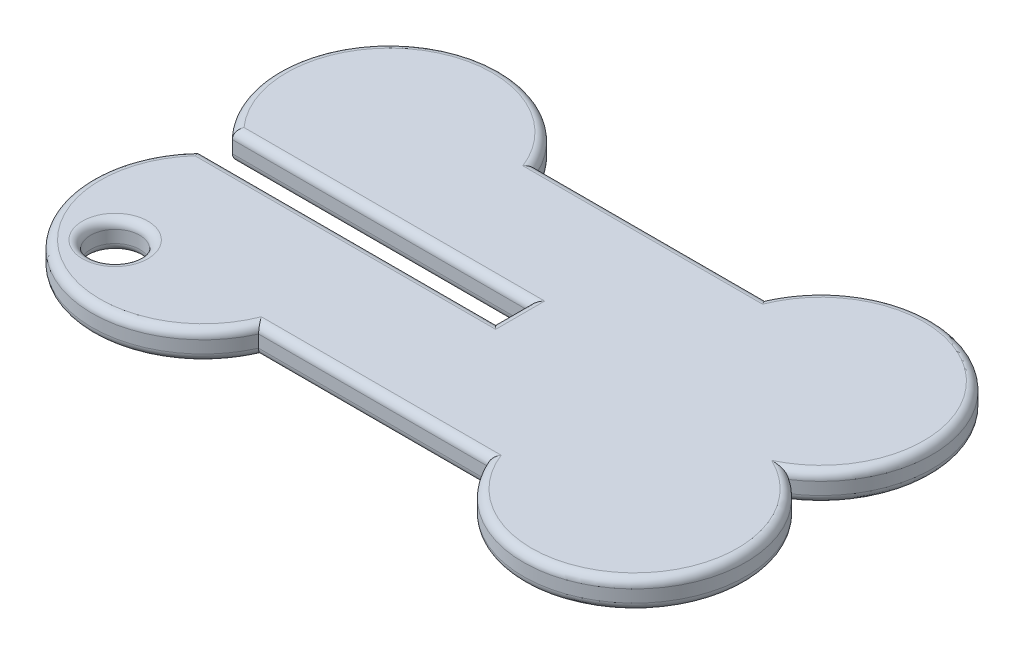
from build123d import *

# Parameters (mm, degrees)
BOSS_EXTRUDE1_DEPTH     = 4.445
SKETCH2_R               = 3.81
CUT_EXTRUDE1_DEPTH      = 152.70955658
CUT_EXTRUDE1_DEPTH_BACK = 152.70955658
FILLET2_R               = 1.27


with BuildPart() as part:
    # Sketch1 → Boss-Extrude1 (new body)
    with BuildSketch(Plane(origin=(0, 0, 0), x_dir=(1, 0, 0), z_dir=(0, 1, 0))):
        with BuildLine():
            Line((-61.139986431, -25.187895035), (-96.716377793, -25.187895035))
            ThreePointArc((-96.716377793, -25.187895035), (-123.704360598, -19.192627404), (-121.874754191, -46.777895035))
            ThreePointArc((-121.874754191, -46.777895035), (-123.704360598, -74.363162665), (-96.716377793, -68.367895035))
            Line((-96.716377793, -68.367895035), (-61.139986431, -68.367895035))
            ThreePointArc((-61.139986431, -68.367895035), (-34.152003626, -74.363162665), (-35.981610034, -46.777895035))
            ThreePointArc((-35.981610034, -46.777895035), (-34.152003626, -19.192627404), (-61.139986431, -25.187895035))
        make_face()
    extrude(amount=BOSS_EXTRUDE1_DEPTH)

    # Sketch2 → Cut-Extrude1 (cut, two sides)
    with BuildSketch(Plane(origin=(0, 4.445, 0), x_dir=(1, 0, 0), z_dir=(0, 1, 0))) as cut_extrude1_sk:
        with BuildLine():
            Line((-78.928182112, -44.237895035), (-124.938415086, -44.237895035))
            ThreePointArc((-124.938415086, -44.237895035), (-123.479984337, -45.596427234), (-121.874754191, -46.777895035))
            ThreePointArc((-121.874754191, -46.777895035), (-123.479984337, -47.959362836), (-124.938415086, -49.317895035))
            Line((-124.938415086, -49.317895035), (-78.928182112, -49.317895035))
            Line((-78.928182112, -49.317895035), (-78.928182112, -44.237895035))
        make_face()
        with Locations(Location((-119.259455088, -68.117887971, 0), (0, 0, 270))):
            Circle(SKETCH2_R)
    extrude(amount=CUT_EXTRUDE1_DEPTH, mode=Mode.SUBTRACT)
    extrude(cut_extrude1_sk.sketch, amount=-CUT_EXTRUDE1_DEPTH_BACK, mode=Mode.SUBTRACT)

    # Fillet2
    fillet2_edges = [part.edges().sort_by_distance(p)[0] for p in [
        (-34.152003626, 0, 19.192627404),
        (-34.152003626, 4.445, 19.192627404),
        (-34.152003626, 0, 74.363162665),
        (-34.152003626, 4.445, 74.363162665),
        (-78.928182112, 0, 25.187895035),
        (-78.928182112, 4.445, 25.187895035),
        (-78.928182112, 0, 68.367895035),
        (-122.119440764, 0, 75.571739971),
        (-101.933298599, 0, 49.317895035),
        (-78.928182112, 0, 46.777895035),
        (-101.933298599, 0, 44.237895035),
        (-122.119440764, 0, 17.984050099),
        (-119.259455088, 0, 64.307887971),
        (-78.928182112, 4.445, 68.367895035),
        (-122.119440764, 4.445, 75.571739971),
        (-101.933298599, 4.445, 49.317895035),
        (-78.928182112, 4.445, 46.777895035),
        (-101.933298599, 4.445, 44.237895035),
        (-122.119440764, 4.445, 17.984050099),
        (-119.259455088, 4.445, 64.307887971),
    ]]
    fillet(fillet2_edges, radius=FILLET2_R)


solid = part.part
